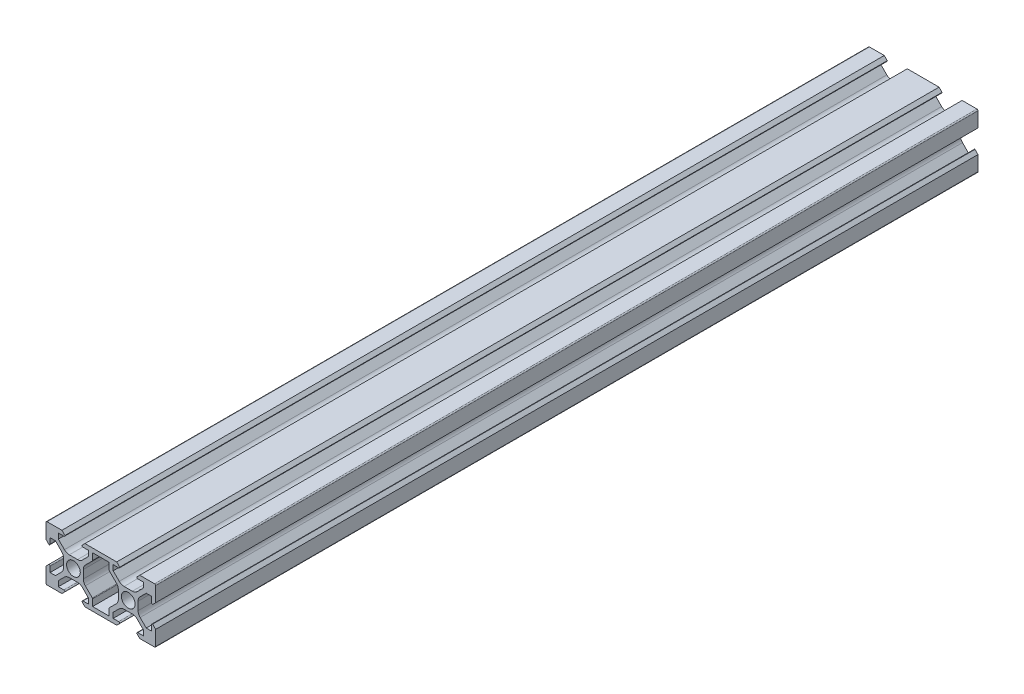
from build123d import *

# Parameters (mm, degrees)
RESSALTO_EXTRUS_O1_DEPTH = 150


with BuildPart() as part:
    # Esboço1 → Ressalto-extrusão1 (new body, symmetric)
    with BuildSketch(Plane.XY):
        with BuildLine():
            Line((-13.1, 8.9), (-14.2, 10))
            Line((-14.2, 10), (-19.6, 10))
            ThreePointArc((-19.6, 10), (-19.882842712, 9.882842712), (-20, 9.6))
            Line((-20, 9.6), (-20, 4.2))
            Line((-20, 4.2), (-18.9, 3.1))
            ThreePointArc((-18.9, 3.1), (-18.617157287, 3.217157287), (-18.5, 3.5))
            Line((-18.5, 3.5), (-18.5, 5.5))
            Line((-18.5, 5.5), (-16.560660172, 5.5))
            Line((-16.560660172, 5.5), (-14.332233047, 3.271572875))
            ThreePointArc((-14.332233047, 3.271572875), (-13.790301169, 2.460514503), (-13.6, 1.503805922))
            Line((-13.6, 1.503805922), (-13.6, 0))
            Line((-13.6, 0), (-13.6, -1.503805922))
            ThreePointArc((-13.6, -1.503805922), (-13.790301169, -2.460514503), (-14.332233047, -3.271572875))
            Line((-14.332233047, -3.271572875), (-16.560660172, -5.5))
            Line((-16.560660172, -5.5), (-18.5, -5.5))
            Line((-18.5, -5.5), (-18.5, -3.5))
            ThreePointArc((-18.5, -3.5), (-18.617157287, -3.217157288), (-18.9, -3.1))
            Line((-18.9, -3.1), (-20, -4.2))
            Line((-20, -4.2), (-20, -9.6))
            ThreePointArc((-20, -9.6), (-19.882842712, -9.882842712), (-19.6, -10))
            Line((-19.6, -10), (-14.2, -10))
            Line((-14.2, -10), (-13.1, -8.9))
            ThreePointArc((-13.1, -8.9), (-13.217157287, -8.617157288), (-13.5, -8.5))
            Line((-13.5, -8.5), (-15.5, -8.5))
            Line((-15.5, -8.5), (-15.5, -6.560660172))
            Line((-15.5, -6.560660172), (-13.271572875, -4.332233047))
            ThreePointArc((-13.271572875, -4.332233047), (-12.460514503, -3.790301169), (-11.503805922, -3.6))
            Line((-11.503805922, -3.6), (-10, -3.6))
            Line((-10, -3.6), (-8.496194078, -3.6))
            ThreePointArc((-8.496194078, -3.6), (-7.539485497, -3.790301169), (-6.728427125, -4.332233047))
            Line((-6.728427125, -4.332233047), (-4.5, -6.560660172))
            Line((-4.5, -6.560660172), (-4.5, -8.5))
            Line((-4.5, -8.5), (-6.5, -8.5))
            ThreePointArc((-6.5, -8.5), (-6.782842712, -8.617157288), (-6.9, -8.9))
            Line((-6.9, -8.9), (-5.8, -10))
            Line((-5.8, -10), (5.8, -10))
            Line((5.8, -10), (6.9, -8.9))
            ThreePointArc((6.9, -8.9), (6.782842712, -8.617157288), (6.5, -8.5))
            Line((6.5, -8.5), (4.5, -8.5))
            Line((4.5, -8.5), (4.5, -6.560660172))
            Line((4.5, -6.560660172), (6.728427125, -4.332233047))
            ThreePointArc((6.728427125, -4.332233047), (7.539485497, -3.790301169), (8.496194078, -3.6))
            Line((8.496194078, -3.6), (10, -3.6))
            Line((10, -3.6), (11.503805922, -3.6))
            ThreePointArc((11.503805922, -3.6), (12.460514503, -3.790301169), (13.271572875, -4.332233047))
            Line((13.271572875, -4.332233047), (15.5, -6.560660172))
            Line((15.5, -6.560660172), (15.5, -8.5))
            Line((15.5, -8.5), (13.5, -8.5))
            ThreePointArc((13.5, -8.5), (13.217157287, -8.617157288), (13.1, -8.9))
            Line((13.1, -8.9), (14.2, -10))
            Line((14.2, -10), (19.6, -10))
            ThreePointArc((19.6, -10), (19.882842712, -9.882842712), (20, -9.6))
            Line((20, -9.6), (20, -4.2))
            Line((20, -4.2), (18.9, -3.1))
            ThreePointArc((18.9, -3.1), (18.617157287, -3.217157288), (18.5, -3.5))
            Line((18.5, -3.5), (18.5, -5.5))
            Line((18.5, -5.5), (16.560660172, -5.5))
            Line((16.560660172, -5.5), (14.332233047, -3.271572875))
            ThreePointArc((14.332233047, -3.271572875), (13.790301169, -2.460514503), (13.6, -1.503805922))
            Line((13.6, -1.503805922), (13.6, 0))
            Line((13.6, 0), (13.6, 1.503805922))
            ThreePointArc((13.6, 1.503805922), (13.790301169, 2.460514503), (14.332233047, 3.271572875))
            Line((14.332233047, 3.271572875), (16.560660172, 5.5))
            Line((16.560660172, 5.5), (18.5, 5.5))
            Line((18.5, 5.5), (18.5, 3.5))
            ThreePointArc((18.5, 3.5), (18.617157287, 3.217157287), (18.9, 3.1))
            Line((18.9, 3.1), (20, 4.2))
            Line((20, 4.2), (20, 9.6))
            ThreePointArc((20, 9.6), (19.882842712, 9.882842712), (19.6, 10))
            Line((19.6, 10), (14.2, 10))
            Line((14.2, 10), (13.1, 8.9))
            ThreePointArc((13.1, 8.9), (13.217157287, 8.617157287), (13.5, 8.5))
            Line((13.5, 8.5), (15.5, 8.5))
            Line((15.5, 8.5), (15.5, 6.560660172))
            Line((15.5, 6.560660172), (13.271572875, 4.332233047))
            ThreePointArc((13.271572875, 4.332233047), (12.460514503, 3.790301169), (11.503805922, 3.6))
            Line((11.503805922, 3.6), (10, 3.6))
            Line((10, 3.6), (8.496194078, 3.6))
            ThreePointArc((8.496194078, 3.6), (7.539485497, 3.790301169), (6.728427125, 4.332233047))
            Line((6.728427125, 4.332233047), (4.5, 6.560660172))
            Line((4.5, 6.560660172), (4.5, 8.5))
            Line((4.5, 8.5), (6.5, 8.5))
            ThreePointArc((6.5, 8.5), (6.782842712, 8.617157288), (6.9, 8.9))
            Line((6.9, 8.9), (5.8, 10))
            Line((5.8, 10), (-5.8, 10))
            Line((-5.8, 10), (-6.9, 8.9))
            ThreePointArc((-6.9, 8.9), (-6.782842712, 8.617157288), (-6.5, 8.5))
            Line((-6.5, 8.5), (-4.5, 8.5))
            Line((-4.5, 8.5), (-4.5, 6.560660172))
            Line((-4.5, 6.560660172), (-6.728427125, 4.332233047))
            ThreePointArc((-6.728427125, 4.332233047), (-7.539485497, 3.790301169), (-8.496194078, 3.6))
            Line((-8.496194078, 3.6), (-10, 3.6))
            Line((-10, 3.6), (-11.503805922, 3.6))
            ThreePointArc((-11.503805922, 3.6), (-12.460514503, 3.790301169), (-13.271572875, 4.332233047))
            Line((-13.271572875, 4.332233047), (-15.5, 6.560660172))
            Line((-15.5, 6.560660172), (-15.5, 8.5))
            Line((-15.5, 8.5), (-13.5, 8.5))
            ThreePointArc((-13.5, 8.5), (-13.217157287, 8.617157287), (-13.1, 8.9))
        make_face()
        with BuildLine():
            Line((-3, 8.5), (3, 8.5))
            Line((3, 8.5), (3, 6.105025253))
            ThreePointArc((3, 6.105025253), (3.030448187, 5.95195188), (3.117157288, 5.822182541))
            Line((3.117157288, 5.822182541), (5.667766953, 3.271572875))
            ThreePointArc((5.667766953, 3.271572875), (6.209698831, 2.460514503), (6.4, 1.503805922))
            Line((6.4, 1.503805922), (6.4, 0))
            Line((6.4, 0), (6.4, -1.503805922))
            ThreePointArc((6.4, -1.503805922), (6.209698831, -2.460514503), (5.667766953, -3.271572875))
            Line((5.667766953, -3.271572875), (3.117157288, -5.822182541))
            ThreePointArc((3.117157288, -5.822182541), (3.030448187, -5.95195188), (3, -6.105025253))
            Line((3, -6.105025253), (3, -8.5))
            Line((3, -8.5), (-3, -8.5))
            Line((-3, -8.5), (-3, -6.105025253))
            ThreePointArc((-3, -6.105025253), (-3.030448187, -5.95195188), (-3.117157288, -5.822182541))
            Line((-3.117157288, -5.822182541), (-5.667766953, -3.271572875))
            ThreePointArc((-5.667766953, -3.271572875), (-6.209698831, -2.460514503), (-6.4, -1.503805922))
            Line((-6.4, -1.503805922), (-6.4, 0))
            Line((-6.4, 0), (-6.4, 1.503805922))
            ThreePointArc((-6.4, 1.503805922), (-6.209698831, 2.460514503), (-5.667766953, 3.271572875))
            Line((-5.667766953, 3.271572875), (-3.117157288, 5.822182541))
            ThreePointArc((-3.117157288, 5.822182541), (-3.030448187, 5.95195188), (-3, 6.105025253))
            Line((-3, 6.105025253), (-3, 8.5))
        make_face(mode=Mode.SUBTRACT)
        with BuildLine():
            ThreePointArc((-10, 2.5), (-11.767766953, 1.767766953), (-12.5, 0))
            ThreePointArc((-12.5, 0), (-11.767766953, -1.767766953), (-10, -2.5))
            ThreePointArc((-10, -2.5), (-8.232233047, -1.767766953), (-7.5, 0))
            ThreePointArc((-7.5, 0), (-8.232233047, 1.767766953), (-10, 2.5))
        make_face(mode=Mode.SUBTRACT)
        with BuildLine():
            ThreePointArc((12.5, 0), (11.767766953, -1.767766953), (10, -2.5))
            ThreePointArc((10, -2.5), (8.232233047, -1.767766953), (7.5, 0))
            ThreePointArc((7.5, 0), (8.232233047, 1.767766953), (10, 2.5))
            ThreePointArc((10, 2.5), (11.767766953, 1.767766953), (12.5, 0))
        make_face(mode=Mode.SUBTRACT)
    extrude(amount=RESSALTO_EXTRUS_O1_DEPTH, both=True)


solid = part.part
